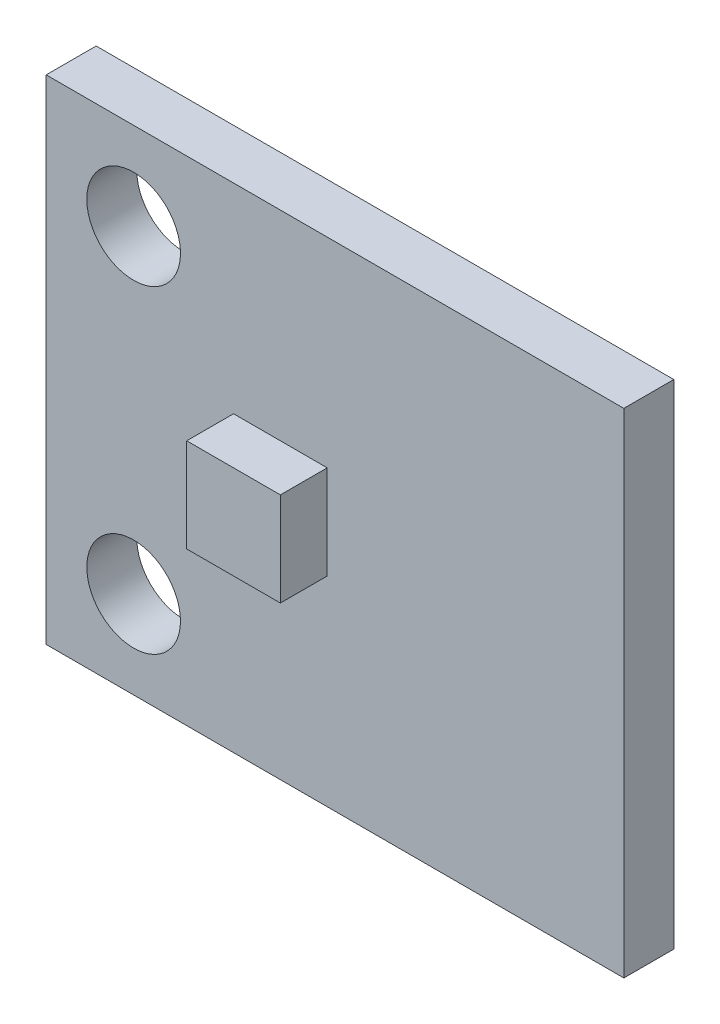
from build123d import *

# Parameters (mm, degrees)
SZKIC1_W                    = 18.5
SZKIC1_H                    = 15.8
DODANIE_WYCI_GNI_CIE1_DEPTH = 1.6
SZKIC2_R                    = 1.5
WYTNIJ_WYCI_GNI_CIE1_DEPTH  = 2.6
SZKIC3_W                    = 3
SZKIC3_H                    = 3
DODANIE_WYCI_GNI_CIE2_DEPTH = 1.5


with BuildPart() as part:
    # Szkic1 → Dodanie-wyciągnięcie1 (new body)
    with BuildSketch(Plane.XY):
        with Locations((9.25, 7.9)):
            Rectangle(SZKIC1_W, SZKIC1_H)
    extrude(amount=DODANIE_WYCI_GNI_CIE1_DEPTH)

    # Szkic2 → Wytnij-wyciągnięcie1 (cut, through all)
    with BuildSketch(Plane(origin=(0, 0, 0), x_dir=(-1, 0, 0), z_dir=(0, 0, -1))):
        with Locations((-2.8, 13)):
            Circle(SZKIC2_R)
        with Locations((-2.8, 2.8)):
            Circle(SZKIC2_R)
    extrude(amount=-WYTNIJ_WYCI_GNI_CIE1_DEPTH, mode=Mode.SUBTRACT)

    # Szkic3 → Dodanie-wyciągnięcie2 (add)
    with BuildSketch(Plane.XY.offset(1.6)):
        with Locations((7.5, 7.9)):
            Rectangle(SZKIC3_W, SZKIC3_H)
    extrude(amount=DODANIE_WYCI_GNI_CIE2_DEPTH)


solid = part.part
